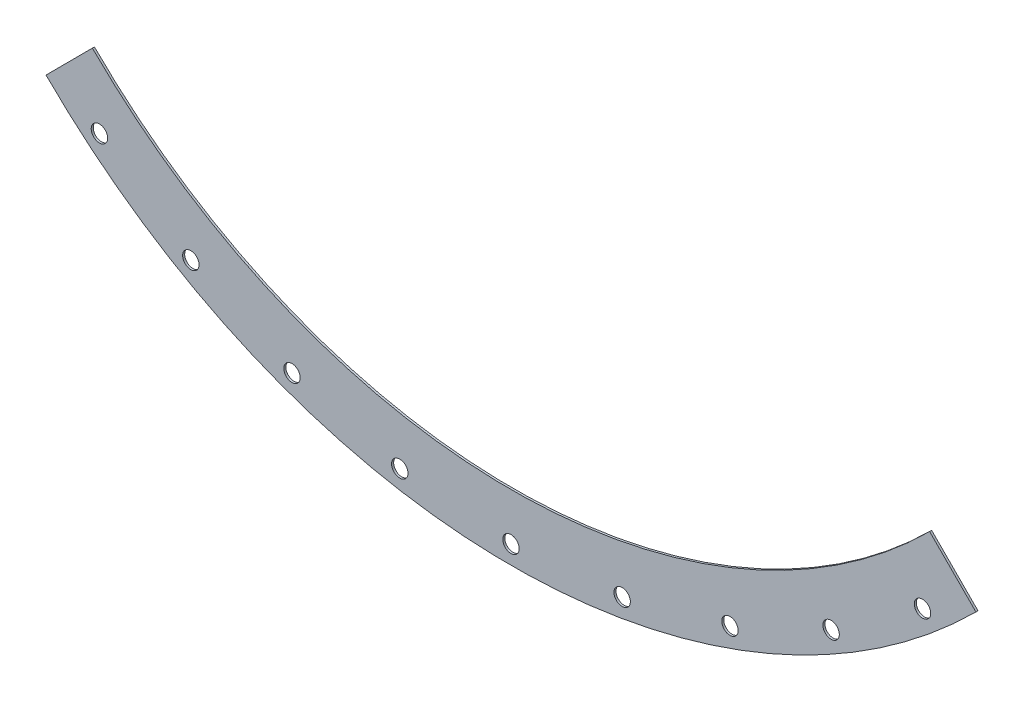
from build123d import *

# Parameters (mm, degrees)
BOSS_EXTRUDE1_DEPTH    = 3.175
F_1_1_DIAMETER_HOLE1_D = 25.4


with BuildPart() as part:
    # Sketch → Boss-Extrude1 (new body)
    with BuildSketch(Plane.XY):
        with BuildLine():
            Line((-647.690106465, -649.9549266), (-719.406658046, -721.922254113))
            ThreePointArc((-719.406658046, -721.922254113), (0, -1019.175), (719.406658046, -721.922254113))
            Line((719.406658046, -721.922254113), (647.690106465, -649.9549266))
            ThreePointArc((647.690106465, -649.9549266), (0, -917.575), (-647.690106465, -649.9549266))
        make_face()
    extrude(amount=BOSS_EXTRUDE1_DEPTH)

    # 1 (1) Diameter Hole1 (through all)
    with Locations(Plane(origin=(-384.964871278, 41.304236103, 3.175), x_dir=(1, 0, 0), z_dir=(0, 0, 1))):
        with Locations((1021.710277433, -800.147861457), (880.264871278, -899.189001092), (723.770025256, -972.163746254), (556.980756074, -1016.854796237), (384.964871278, -1031.904236103), (212.948986481, -1016.854796237), (46.159717299, -972.163746254), (-110.335128722, -899.189001092), (-251.780534878, -800.147861457)):
            Hole(F_1_1_DIAMETER_HOLE1_D / 2)


solid = part.part
